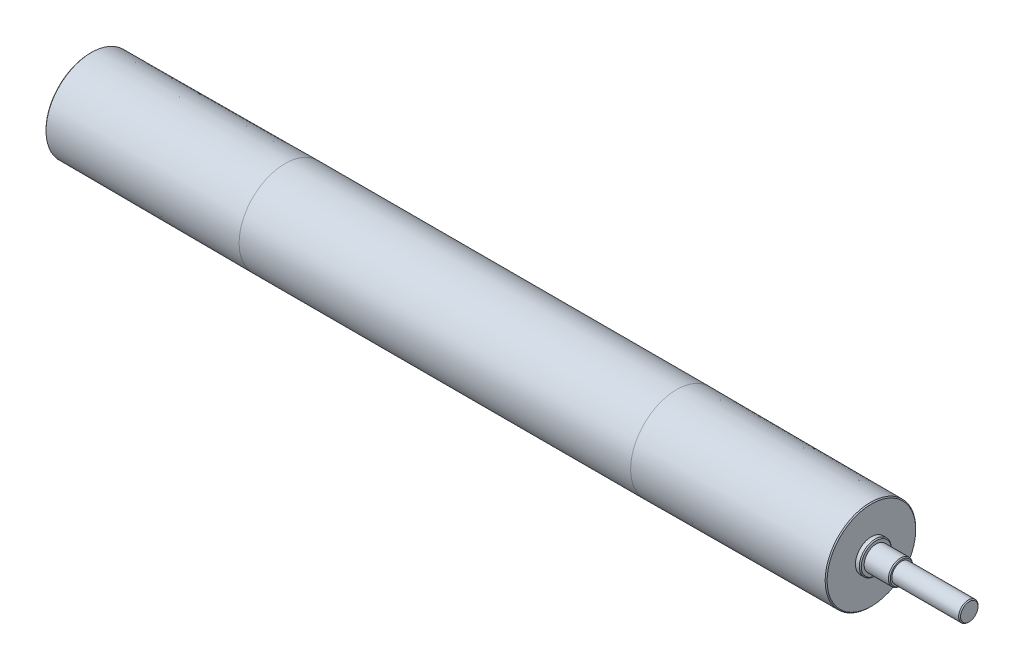
from build123d import *

# Parameters (mm, degrees)
EXTRUDE1_DEPTH = 3.5


with BuildPart() as part:
    # Sketch1 → Revolve1 (revolve)
    with BuildSketch(Plane.XY, mode=Mode.PRIVATE) as revolve1_sk:
        Polygon((-201.999999982, -47.5), (201.999999982, -47.5), (401.999999982, -46.75), (402.999999982, -45.742471769), (402.999999982, -16.5), (406.999999982, -16.5), (407.999999982, -15.5), (407.999999982, -12.5), (432.999999982, -12.5), (433.999999982, -11.5), (433.999999982, -10), (502.999999982, -10), (503.999999982, -9), (503.999999982, 0), (-425.999999982, 0), (-425.999999982, -11.5), (-424.999999982, -12.5), (-407.999999982, -12.5), (-407.999999982, -15.5), (-406.999999982, -16.5), (-402.999999982, -16.5), (-402.999999982, -45.75), (-401.999999982, -46.75), align=None)
    revolve(revolve1_sk.sketch.rotate(Axis((-425.999999982, 0, 0), (1, 0, 0)), 270), axis=Axis((-425.999999982, 0, 0), (1, 0, 0)))  # turned: the seam where the file's is

    # Sketch2 → Extrude1 (cut)
    with BuildSketch(Plane(origin=(468.499999982, 0, -10), x_dir=(0, -1, 0), z_dir=(0, 0, -1))):
        with BuildLine():
            Line((-3, 16.5), (-3, -27.5))
            ThreePointArc((-3, -27.5), (0, -30.5), (3, -27.5))
            Line((3, -27.5), (3, 16.5))
            ThreePointArc((3, 16.5), (0, 19.5), (-3, 16.5))
        make_face()
    extrude(amount=-EXTRUDE1_DEPTH, mode=Mode.SUBTRACT)


solid = part.part
